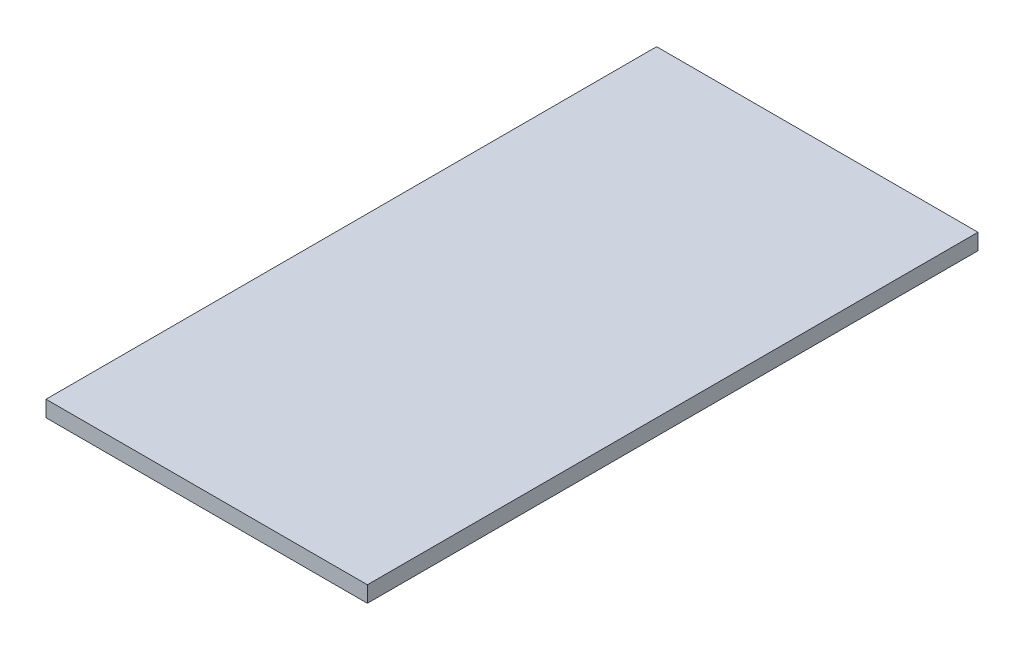
from build123d import *

# Parameters (mm, degrees)
SKETCH1_W           = 20
SKETCH1_H           = 38
BOSS_EXTRUDE1_DEPTH = 1


with BuildPart() as part:
    # Sketch1 → Boss-Extrude1 (new body)
    with BuildSketch(Plane(origin=(0, 0, 0), x_dir=(1, 0, 0), z_dir=(0, 1, 0))):
        Rectangle(SKETCH1_W, SKETCH1_H)
    extrude(amount=BOSS_EXTRUDE1_DEPTH)


solid = part.part
